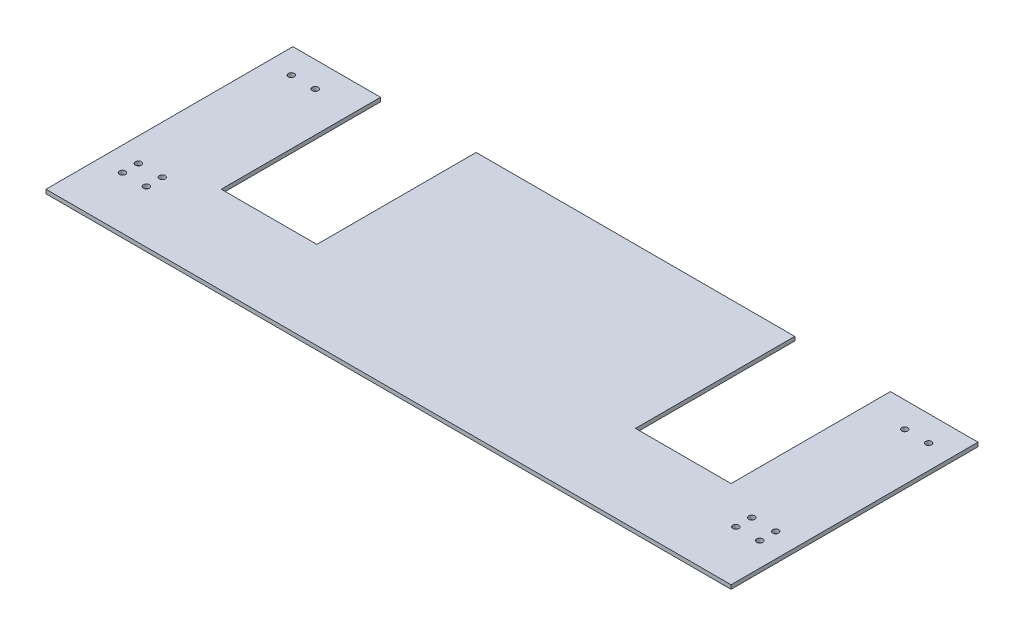
from build123d import *

# Parameters (mm, degrees)
SKETCH1_W           = 546.1
SKETCH1_H           = 3.175
BOSS_EXTRUDE1_DEPTH = 184.15
SKETCH2_R           = 2.413
CUT_EXTRUDE2_DEPTH  = 330.359386727
SKETCH5_W           = 546.1
SKETCH5_H           = 3.175
BOSS_EXTRUDE2_DEPTH = 12.7
SKETCH6_W           = 76.2
SKETCH6_H           = 127
CUT_EXTRUDE4_DEPTH  = 330.359386727
SKETCH7_R           = 2.413
CUT_EXTRUDE5_DEPTH  = 330.359386727


with BuildPart() as part:
    # Sketch1 → Boss-Extrude1 (new body)
    with BuildSketch(Plane.XY):
        Rectangle(SKETCH1_W, SKETCH1_H)
    extrude(amount=BOSS_EXTRUDE1_DEPTH)

    # Sketch2 → Cut-Extrude2 (cut, through all)
    with BuildSketch(Plane(origin=(0, 1.5875, 0), x_dir=(1, 0, 0), z_dir=(0, 1, 0))):
        with Locations((254, -129.54)):
            Circle(SKETCH2_R)
        with Locations((234.95, -129.54)):
            Circle(SKETCH2_R)
        with Locations((-234.95, -129.54)):
            Circle(SKETCH2_R)
        with Locations((-254, -129.54)):
            Circle(SKETCH2_R)
        with Locations((-254, -7.62)):
            Circle(SKETCH2_R)
        with Locations((-234.95, -7.62)):
            Circle(SKETCH2_R)
        with Locations((254, -7.62)):
            Circle(SKETCH2_R)
        with Locations((234.95, -7.62)):
            Circle(SKETCH2_R)
    extrude(amount=-CUT_EXTRUDE2_DEPTH, mode=Mode.SUBTRACT)

    # Sketch5 → Boss-Extrude2 (add)
    with BuildSketch(Plane(origin=(0, 0, 0), x_dir=(-1, 0, 0), z_dir=(0, 0, -1))):
        Rectangle(SKETCH5_W, SKETCH5_H)
    extrude(amount=BOSS_EXTRUDE2_DEPTH)

    # Sketch6 → Cut-Extrude4 (cut, through all)
    with BuildSketch(Plane(origin=(0, 1.5875, 0), x_dir=(1, 0, 0), z_dir=(0, 1, 0))):
        with Locations((165.1, -50.8)):
            Rectangle(SKETCH6_W, SKETCH6_H)
        with Locations((-165.1, -50.8)):
            Rectangle(SKETCH6_W, SKETCH6_H)
    extrude(amount=-CUT_EXTRUDE4_DEPTH, mode=Mode.SUBTRACT)

    # Sketch7 → Cut-Extrude5 (cut, through all)
    with BuildSketch(Plane(origin=(0, 1.5875, 0), x_dir=(1, 0, 0), z_dir=(0, 1, 0))):
        with Locations((-254, -142.24)):
            Circle(SKETCH7_R)
        with Locations((-234.95, -142.24)):
            Circle(SKETCH7_R)
        with Locations((234.95, -142.24)):
            Circle(SKETCH7_R)
        with Locations((254, -142.24)):
            Circle(SKETCH7_R)
    extrude(amount=-CUT_EXTRUDE5_DEPTH, mode=Mode.SUBTRACT)


solid = part.part
